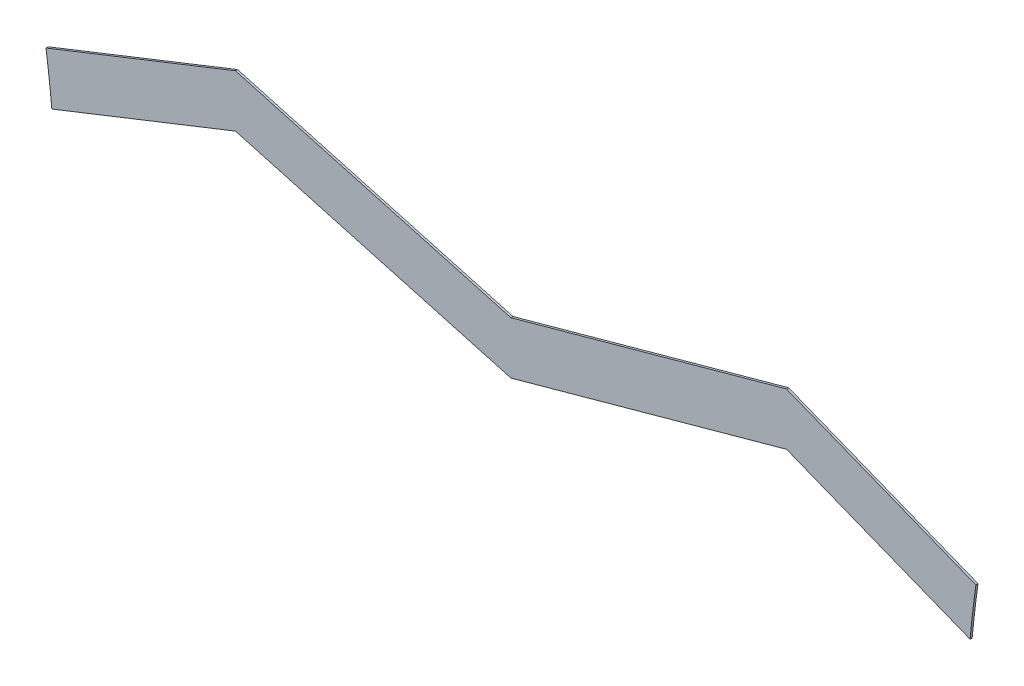
from build123d import *

# Parameters (mm, degrees)
SALIENTE_EXTRUIR1_DEPTH = 0.1


with BuildPart() as part:
    # Model → Saliente-Extruir1 (new body)
    with BuildSketch(Plane.XY):
        with BuildLine():
            Line((59.821558845, 14.577954318), (60.272695606, 14.399362661))
            ThreePointArc((60.272695606, 14.399362661), (60.398521137, 15.595766769), (60.551460532, 16.789007899))
            Line((60.551460532, 16.789007899), (51.49198027, 20.375387298))
            Line((51.49198027, 20.375387298), (38.316142065, 16.736158757))
            Line((38.316142065, 16.736158757), (25.140426213, 20.375830252))
            Line((25.140426213, 20.375830252), (16.080825387, 16.789755425))
            ThreePointArc((16.080825387, 16.789755425), (16.233724667, 15.596509154), (16.359509975, 14.400100817))
            Line((16.359509975, 14.400100817), (16.807003209, 14.577232707))
            Line((16.807003209, 14.577232707), (25.140342166, 17.875830254))
            Line((25.140342166, 17.875830254), (38.316058018, 14.236158759))
            Line((38.316058018, 14.236158759), (51.49198027, 17.875387298))
            Line((51.49198027, 17.875387298), (59.821558845, 14.577954318))
        make_face()
    extrude(amount=SALIENTE_EXTRUIR1_DEPTH)


solid = part.part
